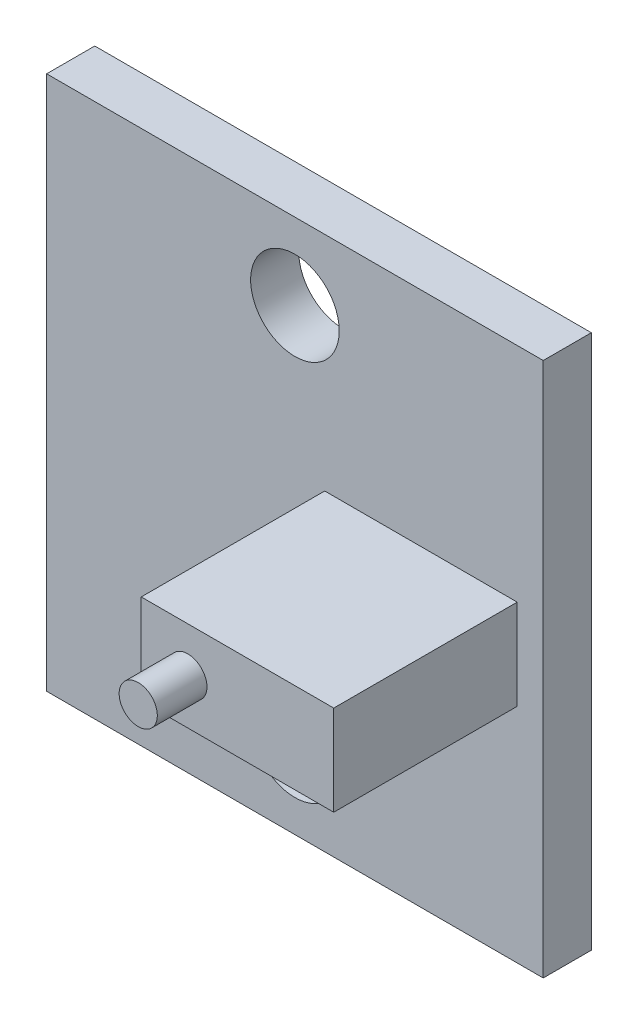
from build123d import *

# Parameters (mm, degrees)
SKETCH1_W                 = 16.51
SKETCH1_H                 = 17.78
BOSS_EXTRUDE1_DEPTH       = 1.6
F_4_CLEARANCE_HOLE1_D     = 2.9464
F_4_CLEARANCE_HOLE1_DEPTH = 6.35
F_4_CLEARANCE_HOLE1_TIP   = 0.885187864
SKETCH4_W                 = 6.4
SKETCH4_H                 = 3
BOSS_EXTRUDE2_DEPTH       = 6.1
SKETCH5_R                 = 0.635
BOSS_EXTRUDE3_DEPTH       = 1.65


with BuildPart() as part:
    # Sketch1 → Boss-Extrude1 (new body)
    with BuildSketch(Plane.XY):
        Rectangle(SKETCH1_W, SKETCH1_H)
    extrude(amount=BOSS_EXTRUDE1_DEPTH)

    # #4 Clearance Hole1
    with Locations(Plane(origin=(0, 6.35, 1.6), x_dir=(1, 0, 0), z_dir=(0, 0, 1))):
        with Locations((0, 0), (0, -12.7)):
            Hole(F_4_CLEARANCE_HOLE1_D / 2, depth=F_4_CLEARANCE_HOLE1_DEPTH)
            with Locations((0, 0, -(F_4_CLEARANCE_HOLE1_DEPTH + F_4_CLEARANCE_HOLE1_TIP / 2))):  # 118° drill point
                Cone(0, F_4_CLEARANCE_HOLE1_D / 2, F_4_CLEARANCE_HOLE1_TIP, mode=Mode.SUBTRACT)

    # Sketch4 → Boss-Extrude2 (add)
    with BuildSketch(Plane.XY.offset(1.6)):
        with Locations((4.19, 0)):
            Rectangle(SKETCH4_W, SKETCH4_H)
    extrude(amount=BOSS_EXTRUDE2_DEPTH)

    # Sketch5 → Boss-Extrude3 (add)
    with BuildSketch(Plane.XY.offset(7.7)):
        with Locations((2.54, 0)):
            Circle(SKETCH5_R)
    extrude(amount=BOSS_EXTRUDE3_DEPTH)


solid = part.part
